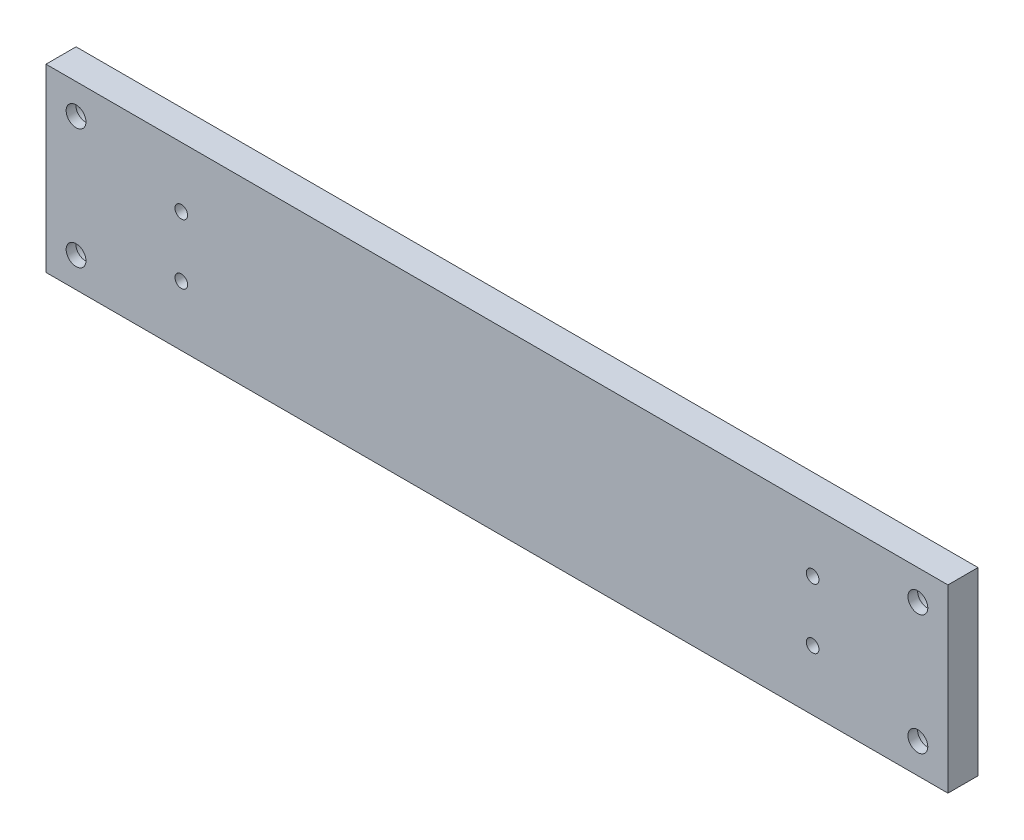
from build123d import *

# Parameters (mm, degrees)
SKETCH_1_W                = 300
SKETCH_1_H                = 60
EXTRUDE_1_DEPTH           = 5
HOLE_WIZARD_M6_1_D        = 5
HOLE_WIZARD_M6_1_DEPTH    = 15
HOLE_WIZARD_M6_1_TIP      = 1.502151548
HOLE_WIZARD_1_D           = 6.6
HOLE_WIZARD_1_CBORE_D     = 11
HOLE_WIZARD_1_CBORE_DEPTH = 6.8
HOLE_WIZARD_M5_1_D        = 4.2


with BuildPart() as part:
    # 草图1 → 凸台-拉伸1 (new body, symmetric)
    with BuildSketch(Plane.XY):
        with Locations((150, -30)):
            Rectangle(SKETCH_1_W, SKETCH_1_H)
    extrude(amount=EXTRUDE_1_DEPTH, both=True)

    # M6 螺纹孔1
    with Locations(Plane(origin=(30, -60, 0), x_dir=(0, 0, -1), z_dir=(0, -1, 0))):
        with Locations((0, 0), (0, 240), (0, 120)):
            Hole(HOLE_WIZARD_M6_1_D / 2, depth=HOLE_WIZARD_M6_1_DEPTH)
            with Locations((0, 0, -(HOLE_WIZARD_M6_1_DEPTH + HOLE_WIZARD_M6_1_TIP / 2))):  # 118° drill point
                Cone(0, HOLE_WIZARD_M6_1_D / 2, HOLE_WIZARD_M6_1_TIP, mode=Mode.SUBTRACT)

    # 打孔尺寸(%根据)内六角圆柱头螺钉的类型1 (through all)
    with Locations(Plane(origin=(10, -10, -5), x_dir=(-1, 0, 0), z_dir=(0, 0, -1))):
        with Locations((0, 0), (0, -40), (-280, 0), (-280, -40)):
            CounterBoreHole(HOLE_WIZARD_1_D / 2, HOLE_WIZARD_1_CBORE_D / 2, HOLE_WIZARD_1_CBORE_DEPTH)

    # M5 螺纹孔1 (through all)
    with Locations(Plane(origin=(45, -20, -5), x_dir=(-1, 0, 0), z_dir=(0, 0, -1))):
        with Locations((0, 0), (0, -20)):
            hole_wizard_m5_1 = Hole(HOLE_WIZARD_M5_1_D / 2)

    # 镜向1: M5 螺纹孔1 across plane
    add(hole_wizard_m5_1.mirror(Plane(origin=(150, 0, 0), x_dir=(0, 0, 1), z_dir=(1, 0, 0))), mode=Mode.SUBTRACT)


solid = part.part
